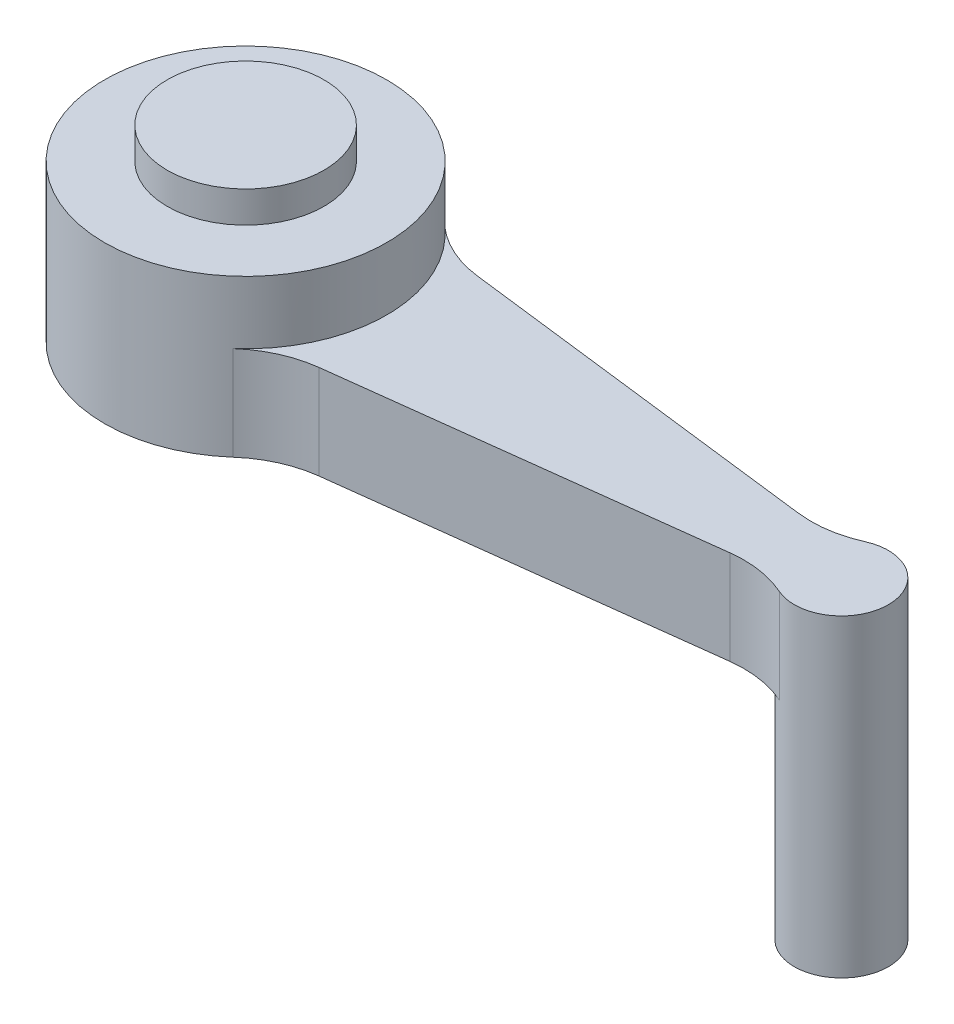
from build123d import *

# Parameters (mm, degrees)
SKETCH1_R                = 4.5
BOSS_EXTRUDE1_DEPTH      = 5
BOSS_EXTRUDE2_DEPTH      = 3
BOSS_EXTRUDE2_DEPTH_BACK = 7
SKETCH1_3_R              = 1.5
BOSS_EXTRUDE3_DEPTH      = 3
SKETCH3_R                = 2.5
BOSS_EXTRUDE4_DEPTH      = 1


with BuildPart() as part:
    # Sketch1 → Boss-Extrude1 (new body)
    with BuildSketch(Plane(origin=(0, 0, 0), x_dir=(1, 0, 0), z_dir=(0, 1, 0))):
        with Locations((-9.5, 0)):
            Circle(SKETCH1_R)
    extrude(amount=BOSS_EXTRUDE1_DEPTH)



with BuildPart() as body_2:
    # Sketch1_3 → Boss-Extrude2 (new, two sides: drawn at the far end of the back side and taken through both)
    with BuildSketch(Plane(origin=(0, 0, 0), x_dir=(1, 0, 0), z_dir=(0, 1, 0)).offset(-BOSS_EXTRUDE2_DEPTH_BACK)):
        with Locations((9.5, 0)):
            Circle(SKETCH1_3_R)
    extrude(amount=BOSS_EXTRUDE2_DEPTH + BOSS_EXTRUDE2_DEPTH_BACK)


with BuildPart() as part_1:
    add(part.part)

    add(body_2.part)  # Boss-Extrude3 merges body 2
    # Sketch2 → Boss-Extrude3 (add)
    with BuildSketch(Plane(origin=(0, 0, 0), x_dir=(1, 0, 0), z_dir=(0, 1, 0))):
        with BuildLine():
            Line((-4.63504008, 2.526088469), (7.037637478, 1.092863881))
            ThreePointArc((7.037637478, 1.092863881), (7.982322779, 1.105340991), (8.889254054, 1.370032623))
            ThreePointArc((8.889254054, 1.370032623), (8, 0), (8.889254054, -1.370032623))
            ThreePointArc((8.889254054, -1.370032623), (7.982322779, -1.105340991), (7.037637478, -1.092863881))
            Line((7.037637478, -1.092863881), (-4.63504008, -2.526088469))
            ThreePointArc((-4.63504008, -2.526088469), (-5.643496055, -2.807700077), (-6.523529775, -3.375))
            ThreePointArc((-6.523529775, -3.375), (-5, 0), (-6.523529775, 3.375))
            ThreePointArc((-6.523529775, 3.375), (-5.643496055, 2.807700077), (-4.63504008, 2.526088469))
        make_face()
    extrude(amount=BOSS_EXTRUDE3_DEPTH)

    # Sketch3 → Boss-Extrude4 (add)
    with BuildSketch(Plane(origin=(0, 5, 0), x_dir=(1, 0, 0), z_dir=(0, 1, 0))):
        with Locations((-9.5, 0)):
            Circle(SKETCH3_R)
    extrude(amount=BOSS_EXTRUDE4_DEPTH)


solid = part_1.part
